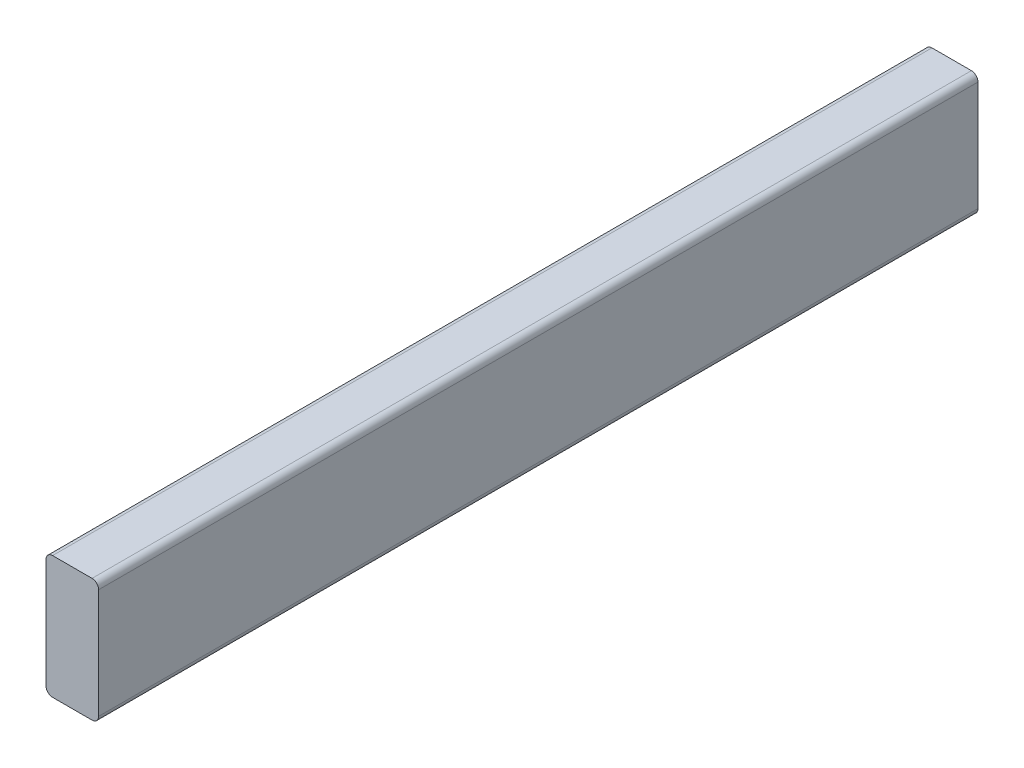
from build123d import *

# Parameters (mm, degrees)
SKETCH1_W           = 38.1
SKETCH1_H           = 88.9
BOSS_EXTRUDE1_DEPTH = 636.669208
FILLET1_R           = 4.7625


with BuildPart() as part:
    # Sketch1 → Boss-Extrude1 (new body)
    with BuildSketch(Plane.XY):
        with Locations((-800.780594651, 56.35625)):
            Rectangle(SKETCH1_W, SKETCH1_H)
    extrude(amount=-BOSS_EXTRUDE1_DEPTH)

    # Fillet1
    fillet1_edges = [part.edges().sort_by_distance(p)[0] for p in [
        (-819.830594651, 11.90625, -318.334604),
        (-819.830594651, 100.80625, -318.334604),
        (-781.730594651, 100.80625, -318.334604),
        (-781.730594651, 11.90625, -318.334604),
    ]]
    fillet(fillet1_edges, radius=FILLET1_R)


solid = part.part
